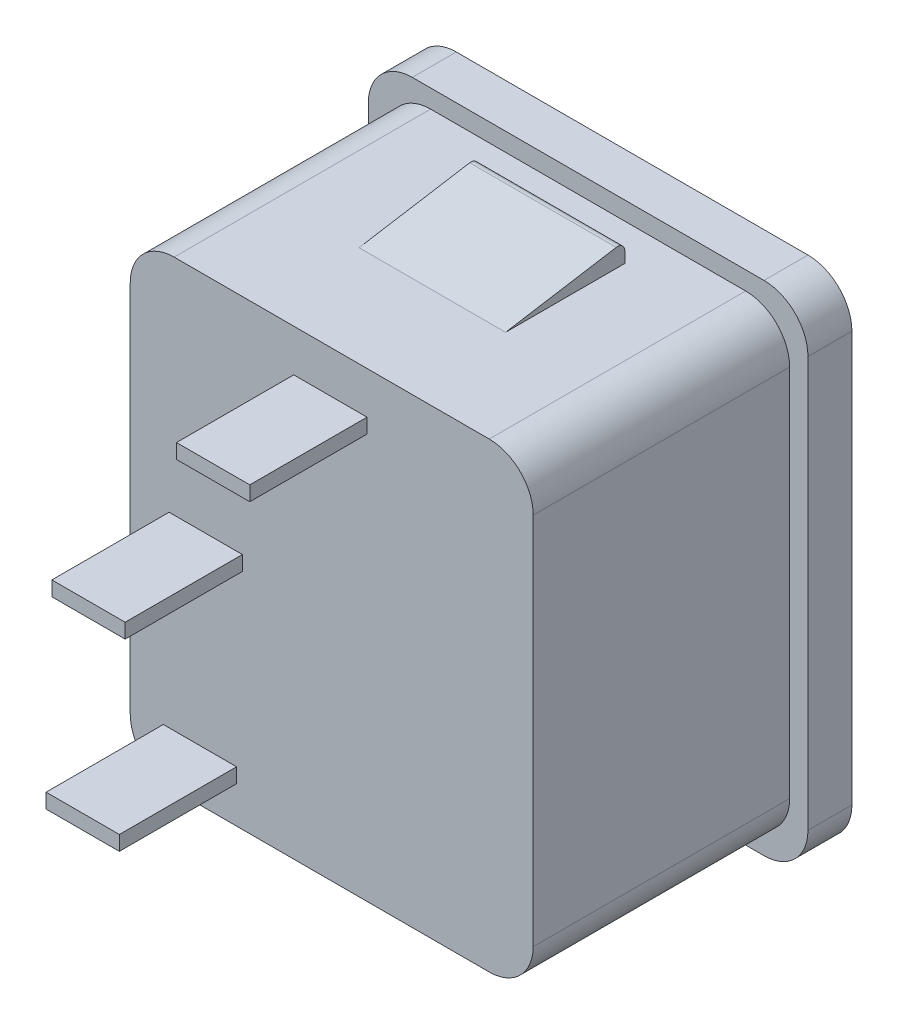
from build123d import *

# Parameters (mm, degrees)
SKETCH1_W           = 30
SKETCH1_H           = 34
BOSS_EXTRUDE1_DEPTH = 3
SKETCH3_W           = 27.5
SKETCH3_H           = 31.5
BOSS_EXTRUDE2_DEPTH = 25.5
FILLET1_R           = 3
BOSS_EXTRUDE3_DEPTH = 5
SKETCH5_OUTSIDE_W   = 42.712
SKETCH5_OUTSIDE_H   = 46.712
SKETCH5_OUTSIDE_W_2 = 5
SKETCH5_OUTSIDE_H_2 = 1
CUT_EXTRUDE1_DEPTH  = 8


with BuildPart() as part:
    # Sketch1 → Boss-Extrude1 (new body)
    with BuildSketch(Plane.XY):
        Rectangle(SKETCH1_W, SKETCH1_H)
    extrude(amount=-BOSS_EXTRUDE1_DEPTH)

    # Sketch3 → Boss-Extrude2 (add)
    with BuildSketch(Plane.XY):
        Rectangle(SKETCH3_W, SKETCH3_H)
    extrude(amount=BOSS_EXTRUDE2_DEPTH)

    # Fillet1
    fillet1_edges = [part.edges().sort_by_distance(p)[0] for p in [
        (13.75, -15.75, 12.75),
        (13.75, 15.75, 12.75),
        (-13.75, 15.75, 12.75),
        (-13.75, -15.75, 12.75),
        (15, -17, -1.5),
        (-15, -17, -1.5),
        (-15, 17, -1.5),
        (15, 17, -1.5),
    ]]
    fillet(fillet1_edges, radius=FILLET1_R)

    # Sketch4 → Boss-Extrude3 (add, symmetric)
    with BuildSketch(Plane(origin=(0, 0, 0), x_dir=(0, 0, -1), z_dir=(1, 0, 0))):
        with BuildLine():
            Line((-2.5, 15.75), (-2.5, 16.5))
            ThreePointArc((-2.5, 16.5), (-2.676424395, 16.881180834), (-3.081195313, 16.993363275))
            Line((-3.081195313, 16.993363275), (-10.636185348, 15.75))
            Line((-10.636185348, 15.75), (-2.5, 15.75))
        make_face()
        with BuildLine():
            Line((-2.5, -15.75), (-10.636185348, -15.75))
            Line((-10.636185348, -15.75), (-3.081195313, -16.993363275))
            ThreePointArc((-3.081195313, -16.993363275), (-2.676424395, -16.881180834), (-2.5, -16.5))
            Line((-2.5, -16.5), (-2.5, -15.75))
        make_face()
    extrude(amount=BOSS_EXTRUDE3_DEPTH, both=True)

    # Sketch5 outside → Cut-Extrude1 (cut)
    with BuildSketch(Plane.XY.offset(25.5)):
        Rectangle(SKETCH5_OUTSIDE_W, SKETCH5_OUTSIDE_H)
        with Locations((-8.597584861, 0)):
            Rectangle(SKETCH5_OUTSIDE_W_2, SKETCH5_OUTSIDE_H_2, mode=Mode.SUBTRACT)
        with Locations((-0.092121408, 12.371641233)):
            Rectangle(SKETCH5_OUTSIDE_W_2, SKETCH5_OUTSIDE_H_2, mode=Mode.SUBTRACT)
        with Locations((-8.993187032, -12.741906988)):
            Rectangle(SKETCH5_OUTSIDE_W_2, SKETCH5_OUTSIDE_H_2, mode=Mode.SUBTRACT)
    extrude(amount=-CUT_EXTRUDE1_DEPTH, mode=Mode.SUBTRACT)


solid = part.part
